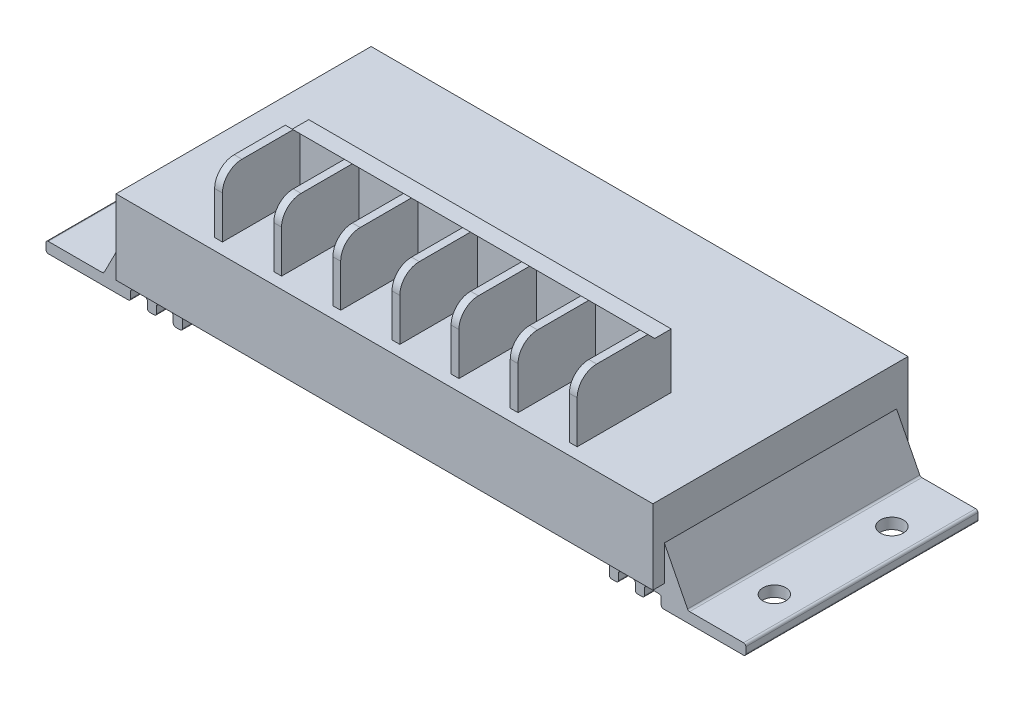
from build123d import *

# Parameters (mm, degrees)
SKETCH1_W           = 117
SKETCH1_H           = 55.6
BOSS_EXTRUDE1_DEPTH = 16.3
SKETCH2_W           = 79
SKETCH2_H           = 23
BOSS_EXTRUDE2_DEPTH = 13.5
SKETCH4_W           = 11.183333333
SKETCH4_H           = 19.4
SKETCH4_W_2         = 11.183333334
CUT_EXTRUDE2_DEPTH  = 13.5
CUT_EXTRUDE1_DEPTH  = 79
BOSS_EXTRUDE3_DEPTH = 50.6
SKETCH7_R           = 2.5
CUT_EXTRUDE3_DEPTH  = 3.35
FILLET1_R           = 0.5


with BuildPart() as part:
    # Sketch1 → Boss-Extrude1 (new body)
    with BuildSketch(Plane(origin=(0, 0, 0), x_dir=(1, 0, 0), z_dir=(0, 1, 0))):
        Rectangle(SKETCH1_W, SKETCH1_H)
    extrude(amount=BOSS_EXTRUDE1_DEPTH)

    # Sketch2 → Boss-Extrude2 (add)
    with BuildSketch(Plane(origin=(0, 16.3, 0), x_dir=(1, 0, 0), z_dir=(0, 1, 0))):
        with Locations((0, -16.3)):
            Rectangle(SKETCH2_W, SKETCH2_H)
    extrude(amount=BOSS_EXTRUDE2_DEPTH)

    # Sketch4 → Cut-Extrude2 (cut)
    with BuildSketch(Plane(origin=(0, 29.8, 0), x_dir=(1, 0, 0), z_dir=(0, 1, 0))):
        with Locations((-32.208333334, -18.1)):
            Rectangle(SKETCH4_W, SKETCH4_H)
        with Locations((-19.325, -18.1)):
            Rectangle(SKETCH4_W_2, SKETCH4_H)
        with Locations((-6.441666667, -18.1)):
            Rectangle(SKETCH4_W, SKETCH4_H)
        with Locations((6.441666667, -18.1)):
            Rectangle(SKETCH4_W, SKETCH4_H)
        with Locations((19.325, -18.1)):
            Rectangle(SKETCH4_W_2, SKETCH4_H)
        with Locations((32.208333334, -18.1)):
            Rectangle(SKETCH4_W, SKETCH4_H)
    extrude(amount=-CUT_EXTRUDE2_DEPTH, mode=Mode.SUBTRACT)

    # Sketch3 → Cut-Extrude1 (cut)
    with BuildSketch(Plane(origin=(39.5, 0, 0), x_dir=(0, 0, -1), z_dir=(1, 0, 0))):
        with BuildLine():
            Line((-27.8, 16.3), (-25.3, 16.3))
            Line((-25.3, 16.3), (-25.3, 25.55))
            ThreePointArc((-25.3, 25.55), (-24.05520382, 28.55520382), (-21.05, 29.8))
            Line((-21.05, 29.8), (-27.8, 29.8))
            Line((-27.8, 29.8), (-27.8, 16.3))
        make_face()
        Polygon((-9.9, 29.8), (-8.4, 28.3), (-4.8, 28.3), (-4.8, 29.8), align=None)
    extrude(amount=-CUT_EXTRUDE1_DEPTH, mode=Mode.SUBTRACT)

    # Sketch5 → Boss-Extrude3 (add)
    with BuildSketch(Plane.XY.offset(25.3)):
        Polygon((-58.5, 7.655574629), (-63.7, -2.55), (-76.25, -2.55), (-76.25, -4.9), (-57.82, -4.9), (-57.82, -2.5), (-54.17, -2.5), (-54.17, -4.9), (-52.17, -4.9), (-52.17, -2.5), (-48.52, -2.5), (-48.52, -4.9), (-46.52, -4.9), (-46.52, 0), (-58.5, 0), align=None)
        Polygon((58.5, 0), (58.5, 7.655574629), (63.7, -2.55), (76.25, -2.55), (76.25, -4.9), (57.82, -4.9), (57.82, -2.5), (54.17, -2.5), (54.17, -4.9), (52.17, -4.9), (52.17, -2.5), (48.52, -2.5), (48.52, -4.9), (46.52, -4.9), (46.52, 0), align=None)
    extrude(amount=-BOSS_EXTRUDE3_DEPTH)

    # Sketch7 → Cut-Extrude3 (cut, through all)
    with BuildSketch(Plane(origin=(0, -2.55, 0), x_dir=(1, 0, 0), z_dir=(0, 1, 0))):
        with Locations((-69.975, 12.8)):
            Circle(SKETCH7_R)
        with Locations((69.975, 12.8)):
            Circle(SKETCH7_R)
        with Locations((69.975, -12.8)):
            Circle(SKETCH7_R)
        with Locations((-69.975, -12.8)):
            Circle(SKETCH7_R)
    extrude(amount=-CUT_EXTRUDE3_DEPTH, mode=Mode.SUBTRACT)

    # Fillet1
    fillet1_edges = [part.edges().sort_by_distance(p)[0] for p in [
        (-46.52, -4.9, 0),
        (-48.52, -4.9, 0),
        (-48.52, -2.5, 0),
        (-52.17, -2.5, 0),
        (-52.17, -4.9, 0),
        (-54.17, -4.9, 0),
        (-54.17, -2.5, 0),
        (-57.82, -2.5, 0),
        (-57.82, -4.9, 0),
        (-76.25, -4.9, 0),
        (-76.25, -2.55, 0),
        (-63.7, -2.55, 0),
        (63.7, -2.55, 0),
        (76.25, -2.55, 0),
        (76.25, -4.9, 0),
        (57.82, -4.9, 0),
        (57.82, -2.5, 0),
        (54.17, -2.5, 0),
        (54.17, -4.9, 0),
        (52.17, -4.9, 0),
        (52.17, -2.5, 0),
        (48.52, -2.5, 0),
        (48.52, -4.9, 0),
        (46.52, -4.9, 0),
    ]]
    fillet(fillet1_edges, radius=FILLET1_R)


solid = part.part
